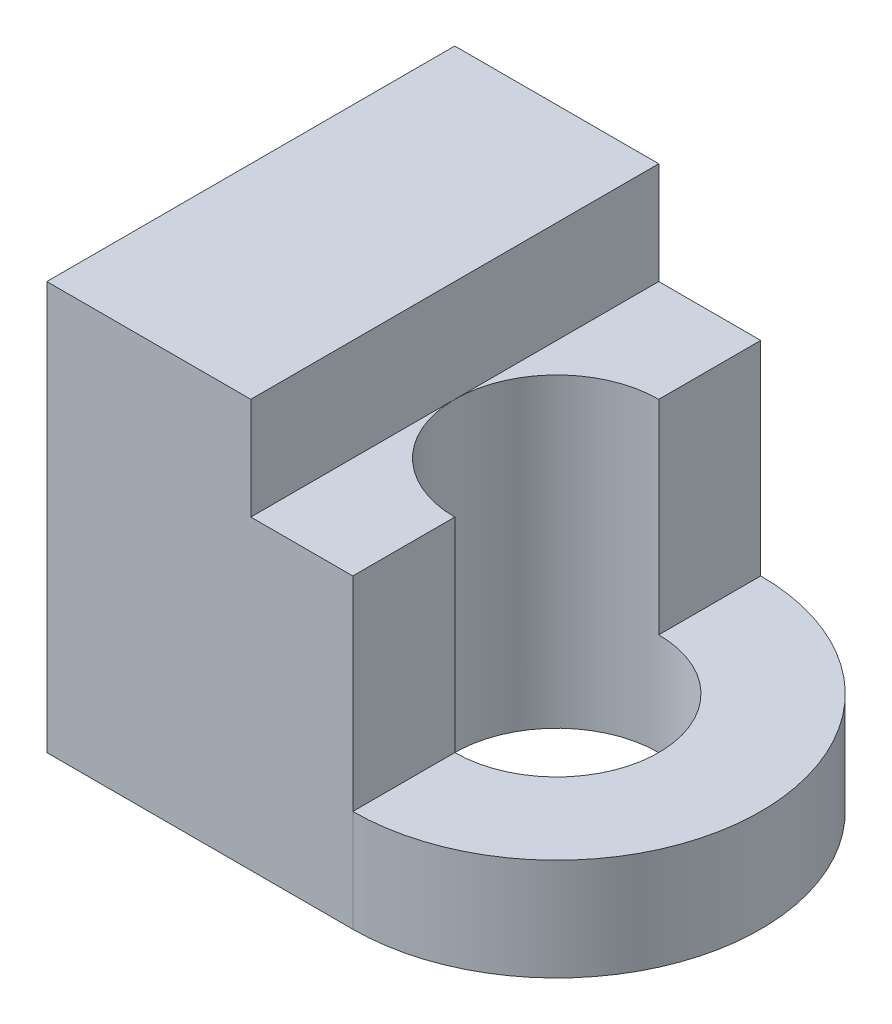
from build123d import *
from build123d.topology import SkipClean

# Parameters (mm, degrees)
SKETCH_1_R      = 5.000000000000002
EXTRUDE_2_DEPTH = 5
EXTRUDE_4_DEPTH = 15
EXTRUDE_5_DEPTH = 20
SCALE_1_SCALE   = 0.2


with BuildPart() as part:
    # 草圖1 → 填料-伸長2 (new body)
    with BuildSketch(Plane(origin=(0, 0, 0), x_dir=(1, 0, 0), z_dir=(0, 1, 0))):
        with BuildLine():
            Line((-15, -10.000000000000002), (0, -10))
            ThreePointArc((0, -10), (10, 2.8e-16), (1.22e-15, 10))
            Line((4.1e-16, 10), (-15, 10))
            Line((-15, 9.999999999999998), (-15, -10.000000000000002))
        make_face()
        Circle(SKETCH_1_R, mode=Mode.SUBTRACT)
    extrude(amount=EXTRUDE_2_DEPTH)

    # 草圖1<4> → 填料-伸長4 (add)
    with BuildSketch(Plane(origin=(0, 0, 0), x_dir=(1, 0, 0), z_dir=(0, 1, 0))):
        with BuildLine():
            Line((-15, -10.000000000000002), (0, -10))
            Line((0, -10), (0, -5))
            ThreePointArc((0, -5), (-5, -3.1e-16), (-6.1e-16, 5))
            Line((0, 5), (0, 10))
            Line((4.1e-16, 10), (-15, 10))
            Line((-15, 9.999999999999998), (-15, -10.000000000000002))
        make_face()
    extrude(amount=EXTRUDE_4_DEPTH)

    # 草圖1<5> → 填料-伸長5 (add)
    with SkipClean():  # the faces are left unmerged after this step: merging them gives an invalid solid
        with BuildSketch(Plane(origin=(0, 0, 0), x_dir=(1, 0, 0), z_dir=(0, 1, 0))):
            Polygon((-15, -10.000000000000002), (-5, -10), (-5, -3.55e-15), (-5, 10), (-15, 10), align=None)
        extrude(amount=EXTRUDE_5_DEPTH)


with BuildPart() as part_1:
    # 縮放比例1: scaled about (-7.196969697, 8.78268307, 0)
    add(part.part.scale(SCALE_1_SCALE).moved(Location((-5.757575757600001, 7.026146455999999, 0))))


solid = part_1.part
